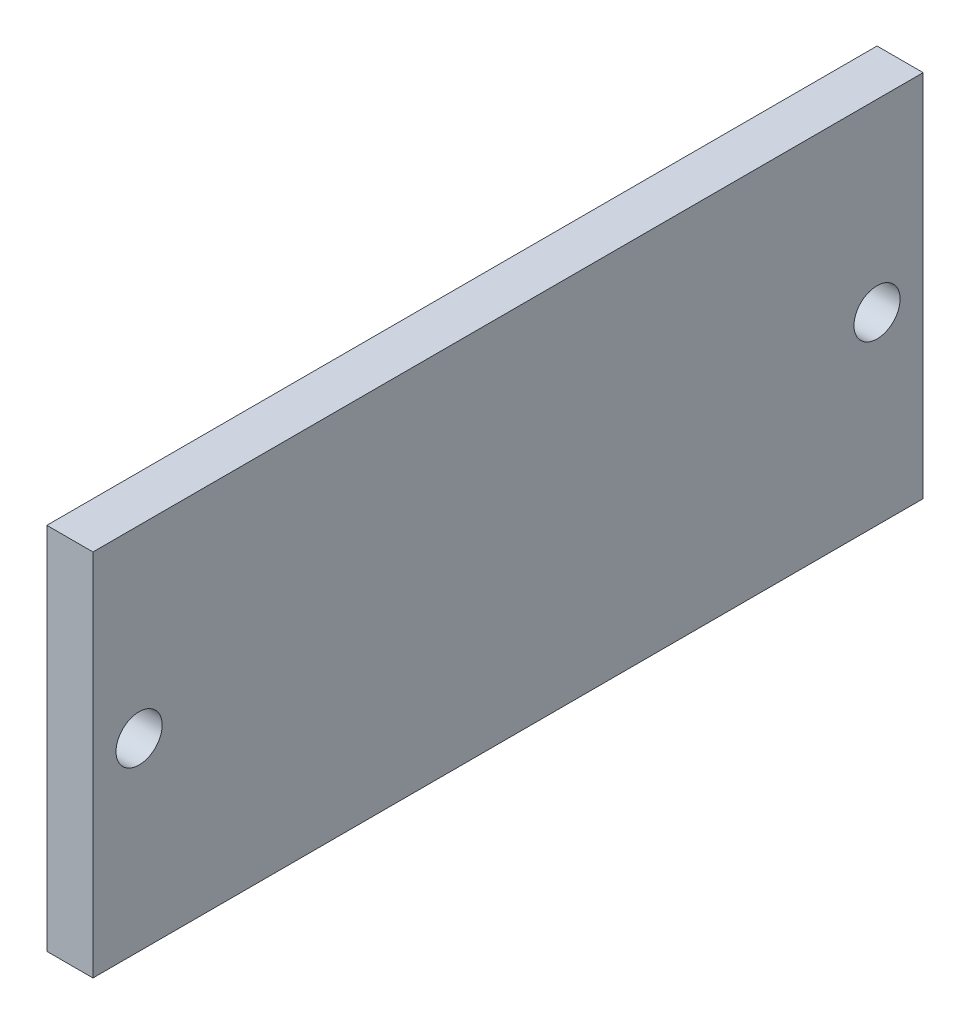
from build123d import *

# Parameters (mm, degrees)
SKETCH1_W           = 457.2
SKETCH1_H           = 203.2
BOSS_EXTRUDE1_DEPTH = 12.7
CUT_EXTRUDE1_START  = -26.4
SKETCH2_R           = 12.7
CUT_EXTRUDE1_DEPTH  = 27.4


with BuildPart() as part:
    # Sketch1 → Boss-Extrude1 (new body, symmetric)
    with BuildSketch(Plane(origin=(0, 0, 0), x_dir=(0, 0, -1), z_dir=(1, 0, 0))):
        with Locations((228.6, 101.6)):
            Rectangle(SKETCH1_W, SKETCH1_H)
    extrude(amount=BOSS_EXTRUDE1_DEPTH, both=True)

    # Sketch2 → Cut-Extrude1 (cut)
    with BuildSketch(Plane.ZY.offset(12.7).offset(CUT_EXTRUDE1_START)):
        with Locations((-431.8, 101.6)):
            Circle(SKETCH2_R)
    cut_extrude1 = extrude(amount=CUT_EXTRUDE1_DEPTH, mode=Mode.SUBTRACT)

    # Mirror3: Cut-Extrude1 across plane
    add(cut_extrude1.mirror(Plane.XY.offset(-228.6)), mode=Mode.SUBTRACT)


solid = part.part
